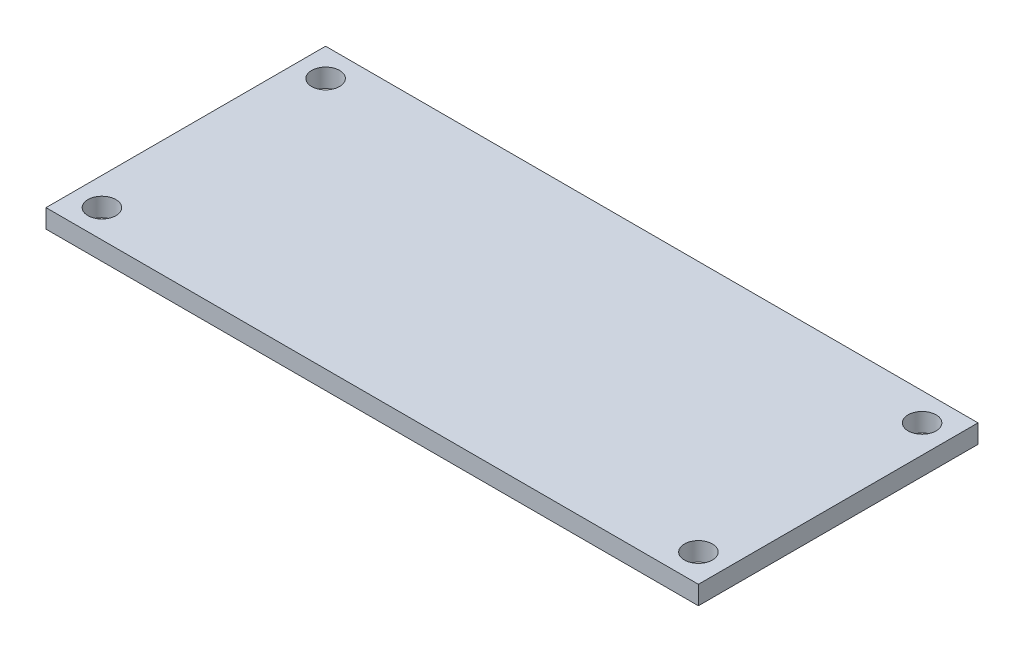
from build123d import *

# Parameters (mm, degrees)
SKETCH1_W           = 70
SKETCH1_H           = 30
BOSS_EXTRUDE1_DEPTH = 2
SKETCH2_R           = 1.5
CUT_EXTRUDE1_DEPTH  = 2


with BuildPart() as part:
    # Sketch1 → Boss-Extrude1 (new body)
    with BuildSketch(Plane(origin=(0, 0, 0), x_dir=(1, 0, 0), z_dir=(0, 1, 0))):
        Rectangle(SKETCH1_W, SKETCH1_H)
    extrude(amount=BOSS_EXTRUDE1_DEPTH)

    # Sketch2 → Cut-Extrude1 (cut)
    with BuildSketch(Plane(origin=(0, 2, 0), x_dir=(1, 0, 0), z_dir=(0, 1, 0))):
        with Locations((-32, 12)):
            Circle(SKETCH2_R)
        with Locations((-32, -12)):
            Circle(SKETCH2_R)
        with Locations((32, -12)):
            Circle(SKETCH2_R)
        with Locations((32, 12)):
            Circle(SKETCH2_R)
    extrude(amount=-CUT_EXTRUDE1_DEPTH, mode=Mode.SUBTRACT)


solid = part.part
